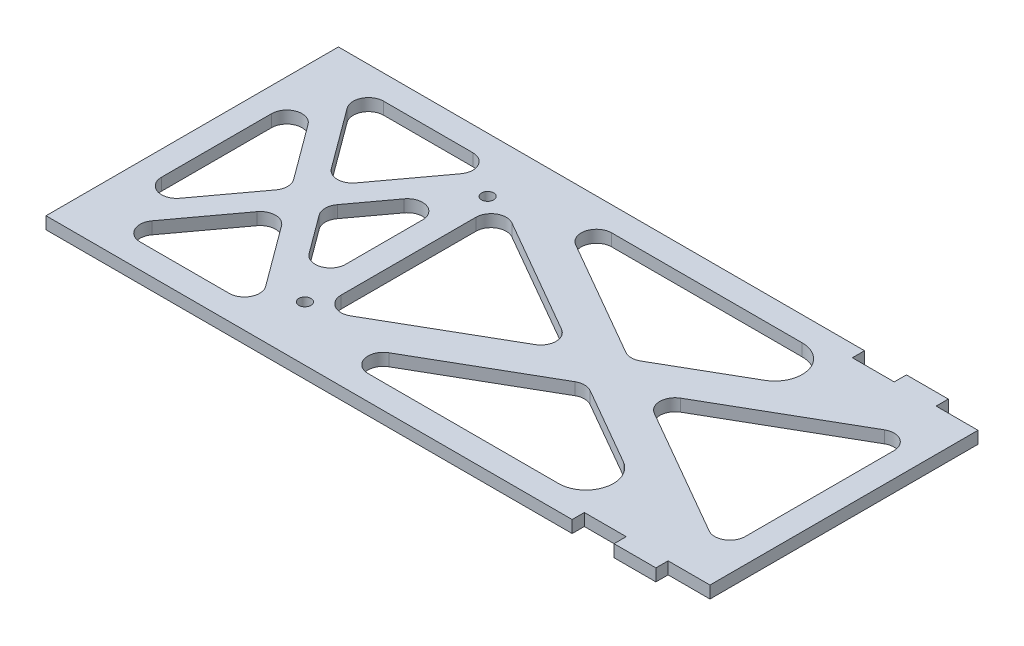
from build123d import *

# Parameters (mm, degrees)
SKETCH1_W           = 271.78
SKETCH1_H           = 121.92
SKETCH1_R           = 2.54
BOSS_EXTRUDE1_DEPTH = 5.08
FILLET1_R           = 6.35
SKETCH3_W           = 17.4625
SKETCH3_H           = 5.08
CUT_EXTRUDE2_DEPTH  = 7.62
FILLET2_R           = 11.43


with BuildPart() as part:
    # Sketch1 → Boss-Extrude1 (new body)
    with BuildSketch(Plane(origin=(0, 0, 0), x_dir=(1, 0, 0), z_dir=(0, 1, 0))):
        Rectangle(SKETCH1_W, SKETCH1_H)
        with Locations((-50.8, -38.1)):
            Circle(SKETCH1_R, mode=Mode.SUBTRACT)
        Polygon((-125.73, 42.241214341), (-94.577104423, 0), (-125.73, -42.241214341), align=None, mode=Mode.SUBTRACT)
        Polygon((-88.265, -8.558785659), (-57.112104423, -50.8), (-119.417895577, -50.8), align=None, mode=Mode.SUBTRACT)
        Polygon((-55.88, -35.353078748), (-81.952895577, 0), (-55.88, 35.353078748), align=None, mode=Mode.SUBTRACT)
        Polygon((-35.524026052, -50.8), (37.465, -8.791927452), (110.454026052, -50.8), align=None, mode=Mode.SUBTRACT)
        Polygon((22.189026052, 0), (-45.72, -39.084331541), (-45.72, 39.084331541), align=None, mode=Mode.SUBTRACT)
        Polygon((-57.112104423, 50.8), (-88.265, 8.558785659), (-119.417895577, 50.8), align=None, mode=Mode.SUBTRACT)
        with Locations((-50.8, 38.1)):
            Circle(SKETCH1_R, mode=Mode.SUBTRACT)
        Polygon((52.740973948, 0), (125.73, 42.008072548), (125.73, -42.008072548), align=None, mode=Mode.SUBTRACT)
        Polygon((110.454026052, 50.8), (37.465, 8.791927452), (-35.524026052, 50.8), align=None, mode=Mode.SUBTRACT)
    extrude(amount=BOSS_EXTRUDE1_DEPTH)

    # Fillet1
    fillet1_edges = [part.edges().sort_by_distance(p)[0] for p in [
        (-35.524026052, 2.54, 50.8),
        (37.465, 2.54, 8.791927452),
        (125.73, 2.54, 42.008072548),
        (125.73, 2.54, -42.008072548),
        (52.740973948, 2.54, 0),
        (-45.72, 2.54, 39.084331541),
        (22.189026052, 2.54, 0),
        (-45.72, 2.54, -39.084331541),
        (-35.524026052, 2.54, -50.8),
        (37.465, 2.54, -8.791927452),
        (-125.73, 2.54, -42.241214341),
        (-125.73, 2.54, 42.241214341),
        (-94.577104423, 2.54, 0),
        (-57.112104423, 2.54, -50.8),
        (-119.417895577, 2.54, -50.8),
        (-88.265, 2.54, -8.558785659),
        (-119.417895577, 2.54, 50.8),
        (-57.112104423, 2.54, 50.8),
        (-88.265, 2.54, 8.558785659),
        (-55.88, 2.54, 35.353078748),
        (-55.88, 2.54, -35.353078748),
        (-81.952895577, 2.54, 0),
    ]]
    fillet(fillet1_edges, radius=FILLET1_R)

    # Sketch3 → Cut-Extrude2 (cut)
    with BuildSketch(Plane(origin=(0, 5.08, 0), x_dir=(1, 0, 0), z_dir=(0, 1, 0))):
        with Locations((92.23375, 58.42)):
            Rectangle(SKETCH3_W, SKETCH3_H)
        with Locations((127.15875, 58.42)):
            Rectangle(SKETCH3_W, SKETCH3_H)
        with Locations((92.23375, -58.42)):
            Rectangle(SKETCH3_W, SKETCH3_H)
        with Locations((127.15875, -58.42)):
            Rectangle(SKETCH3_W, SKETCH3_H)
    extrude(amount=-CUT_EXTRUDE2_DEPTH, mode=Mode.SUBTRACT)

    # Fillet2
    fillet2_edges = [part.edges().sort_by_distance(p)[0] for p in [
        (110.454026052, 2.54, 50.8),
        (110.454026052, 2.54, -50.8),
    ]]
    fillet(fillet2_edges, radius=FILLET2_R)


solid = part.part
